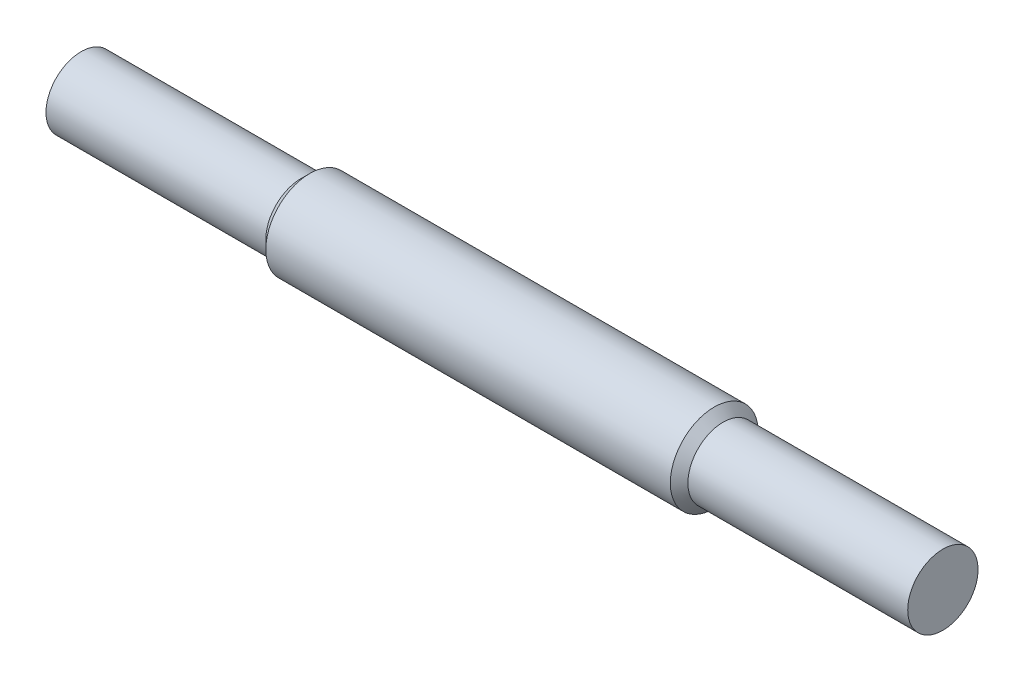
from build123d import *


with BuildPart() as part:
    # Szkic1 → Obrót1 (revolve)
    with BuildSketch(Plane(origin=(0, 0, 0), x_dir=(1, 0, 0), z_dir=(0, 1, 0))):
        Polygon((-25, 0), (23, 0), (48, 0), (48, 4), (23, 4), (22, 5), (-24, 5), (-25, 4), (-50, 4), (-50, 0), align=None)
    revolve(axis=Axis((-25, 0, 0), (1, 0, 0)))


solid = part.part
